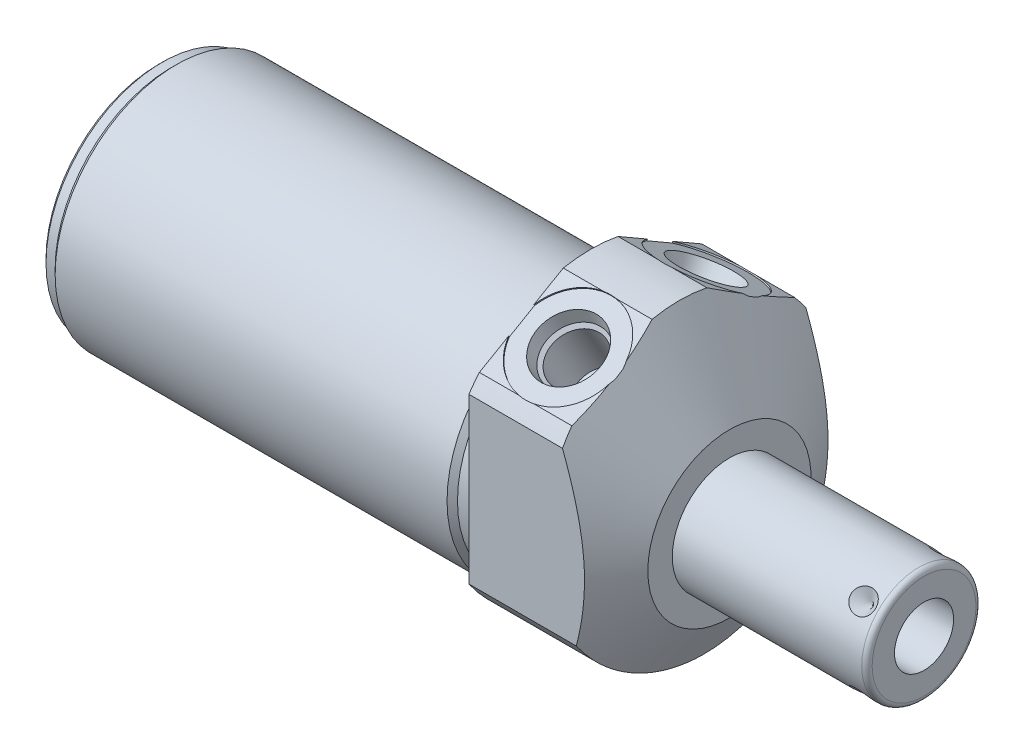
from build123d import *

# Parameters (mm, degrees)
SKETCH1_R           = 28.575
EXTRUDE1_DEPTH      = 27.0002
EXTRUDE1_DEPTH_BACK = 84.1248
CUT_EXTRUDE1_REACH  = 86.125
SKETCH2_R           = 28.575
SKETCH2_R_2         = 23.622
CUT_EXTRUDE3_START  = -27.0002
CUT_EXTRUDE3_DEPTH  = 27.0002
SKETCH18_R          = 9.525
CUT_EXTRUDE4_DEPTH  = 0.254
SKETCH19_R          = 9.525
CUT_EXTRUDE5_DEPTH  = 0.254
CHAMFER1_SIZE       = 0.762
CIRPATTERN1_COUNT   = 4


with BuildPart() as part:
    # Sketch1 → Extrude1 (new body, two sides)
    with BuildSketch(Plane(origin=(0, 0, 0), x_dir=(0, 0, -1), z_dir=(1, 0, 0))) as extrude1_sk:
        Circle(SKETCH1_R)
    extrude(amount=EXTRUDE1_DEPTH)
    extrude(extrude1_sk.sketch, amount=-EXTRUDE1_DEPTH_BACK)

    # Sketch2 → Cut-Extrude1 (cut, up to next)
    with BuildSketch(Plane(origin=(0, 0, 0), x_dir=(0, 0, -1), z_dir=(1, 0, 0)), mode=Mode.PRIVATE) as cut_extrude1_sk1:
        Circle(SKETCH2_R)
        with Locations((0, -4.191)):
            Circle(SKETCH2_R_2, mode=Mode.SUBTRACT)
    cut_extrude1_tool1 = extrude(cut_extrude1_sk1.sketch, amount=-CUT_EXTRUDE1_REACH, mode=Mode.PRIVATE) & part.part
    add(cut_extrude1_tool1.solids().sort_by_distance((0, 0, 27.766777))[0], mode=Mode.SUBTRACT)

    # Sketch4 → Cut-Extrude3 (cut)
    with BuildSketch(Plane.ZY.offset(CUT_EXTRUDE3_START)):
        with BuildLine():
            Line((23.6855, -25.666178421), (23.6855, 17.476089577))
            Line((23.6855, 17.476089577), (0, 31.150919378))
            Line((0, 31.150919378), (-23.6855, 17.476089577))
            Line((-23.6855, 17.476089577), (-23.6855, -25.666178421))
            ThreePointArc((-23.6855, -25.666178421), (0, 34.925), (23.6855, -25.666178421))
        make_face()
    extrude(amount=CUT_EXTRUDE3_DEPTH, mode=Mode.SUBTRACT)

    # Sketch6 → Cut-Revolve2 (revolve, cut)
    with BuildSketch(Plane.XY, mode=Mode.PRIVATE) as cut_revolve2_sk:
        Polygon((0.750392661, 57.15), (27.0002, 11.684), (27.0002, 57.15), align=None)
    revolve(cut_revolve2_sk.sketch.rotate(Axis((-0.562097706, -4.191, 0), (1, 0, 0)), 270), axis=Axis((-0.562097706, -4.191, 0), (1, 0, 0)), mode=Mode.SUBTRACT)  # turned: the seam where the file's is

    # S2D0002 → Cut-Revolve3 (revolve, cut)
    with BuildSketch(Plane(origin=(9.0932, 23.136869081, 13.372742289), x_dir=(0, 0.5, -0.866025404), z_dir=(1, 0, 0))):
        Polygon((0, 0), (6.1849, 0), (5.642306865, -2.5527), (4.9784, -3.216606865), (4.9784, -13.462), (0, -13.462), align=None)
    revolve(axis=Axis((9.0932, 10.895513396, 6.305192289), (0, 0.866025404, 0.5)), mode=Mode.SUBTRACT)

    # Sketch8 → Cut-Revolve4 (revolve, cut)
    with BuildSketch(Plane(origin=(9.0932, 23.136869081, -13.372742289), x_dir=(0, -0.5, -0.866025404), z_dir=(1, 0, 0))):
        Polygon((0, 0), (6.1849, 0), (5.642306865, -2.5527), (4.9784, -3.216606865), (4.9784, -13.462), (0, -13.462), align=None)
    revolve(axis=Axis((9.0932, 10.895513396, -6.305192289), (0, 0.866025404, -0.5)), mode=Mode.SUBTRACT)

    # Sketch18 → Cut-Extrude4 (cut)
    with BuildSketch(Plane(origin=(0, 23.363189534, 13.488743766), x_dir=(1, 0, 0), z_dir=(0, 0.866025404, 0.5))):
        with Locations((9.0932, -0.0127)):
            Circle(SKETCH18_R)
    extrude(amount=-CUT_EXTRUDE4_DEPTH, mode=Mode.SUBTRACT)

    # Sketch19 → Cut-Extrude5 (cut)
    with BuildSketch(Plane(origin=(0, 23.363189534, -13.488743766), x_dir=(1, 0, 0), z_dir=(0, 0.866025404, -0.5))):
        with Locations((9.0932, 0.0127)):
            Circle(SKETCH19_R)
    extrude(amount=-CUT_EXTRUDE5_DEPTH, mode=Mode.SUBTRACT)

    # Sketch10 → Cut-Revolve6 (revolve, cut)
    with BuildSketch(Plane.XY, mode=Mode.PRIVATE) as cut_revolve6_sk:
        Polygon((0, 19.431), (0, 18.415), (-3.302, 18.415), (-4.318, 19.431), align=None)
    revolve(cut_revolve6_sk.sketch.rotate(Axis((-4.5339, -4.191, 0), (1, 0, 0)), 90), axis=Axis((-4.5339, -4.191, 0), (1, 0, 0)), mode=Mode.SUBTRACT)  # turned: the seam where the file's is

    # Sketch12 → Cut-Revolve8 (revolve, cut)
    with BuildSketch(Plane.XY, mode=Mode.PRIVATE) as cut_revolve8_sk:
        Polygon((-84.1248, 19.431), (-84.1248, 18.415), (-81.5848, 18.415), (-80.5688, 19.431), align=None)
    revolve(cut_revolve8_sk.sketch.rotate(Axis((-84.3026, -4.191, 0), (1, 0, 0)), 90), axis=Axis((-84.3026, -4.191, 0), (1, 0, 0)), mode=Mode.SUBTRACT)  # turned: the seam where the file's is

    # Chamfer1
    chamfer1_edges = [part.edges().sort_by_distance(p)[0] for p in [
        (-84.1248, -4.191, -22.606),
    ]]
    chamfer(chamfer1_edges, length=CHAMFER1_SIZE)

    # Sketch13 → Revolve1 (revolve)
    with BuildSketch(Plane(origin=(0, 0, 0), x_dir=(0, -1, 0), z_dir=(0, 0, 1)), mode=Mode.PRIVATE) as revolve1_sk:
        with BuildLine():
            Line((4.191, 27.0002), (4.191, 64.8716))
            Line((4.191, 64.8716), (14.2875, 64.8716))
            ThreePointArc((14.2875, 64.8716), (15.00592049, 64.57402049), (15.3035, 63.8556))
            Line((15.3035, 63.8556), (15.3035, 27.0002))
            Line((15.3035, 27.0002), (4.191, 27.0002))
        make_face()
    revolve(revolve1_sk.sketch.rotate(Axis((25.10663, -4.191, 0), (1, 0, 0)), 270), axis=Axis((25.10663, -4.191, 0), (1, 0, 0)))  # turned: the seam where the file's is

    # S2D0001 → Cut-Revolve9 (revolve, cut)
    with BuildSketch(Plane(origin=(64.8716, -9.9441, 0), x_dir=(0, -1, 0), z_dir=(0, 0, 1)), mode=Mode.PRIVATE) as cut_revolve9_sk:
        Polygon((0, 0), (0, -17.018), (-5.7531, -20.474811227), (-5.7531, 0), align=None)
    revolve(cut_revolve9_sk.sketch.rotate(Axis((43.373048211, -4.191, 0), (1, 0, 0)), 270), axis=Axis((43.373048211, -4.191, 0), (1, 0, 0)), mode=Mode.SUBTRACT)  # turned: the seam where the file's is

    # Sketch16 → Cut-Revolve10 (revolve, cut)
    with BuildSketch(Plane(origin=(60.9092, 3.666724106, -7.857724106), x_dir=(-1, 0, 0), z_dir=(0, -0.707106781, -0.707106781)), mode=Mode.PRIVATE) as cut_revolve10_sk:
        Polygon((0, 0), (2.413, 0), (0, -2.413), align=None)
    cut_revolve10 = revolve(cut_revolve10_sk.sketch.rotate(Axis((60.9092, 0.494324135, -4.685324135), (0, 0.707106781, -0.707106781)), 90), axis=Axis((60.9092, 0.494324135, -4.685324135), (0, 0.707106781, -0.707106781)), mode=Mode.SUBTRACT)  # turned: the seam where the file's is

    # CirPattern1: Cut-Revolve10 ×4 about axis
    cirpattern1_axis = Axis((25.10663, -4.191, 0), (-1, 0, 0))
    for i in range(1, CIRPATTERN1_COUNT):
        add(cut_revolve10.rotate(cirpattern1_axis, i * 360 / CIRPATTERN1_COUNT), mode=Mode.SUBTRACT)


solid = part.part
